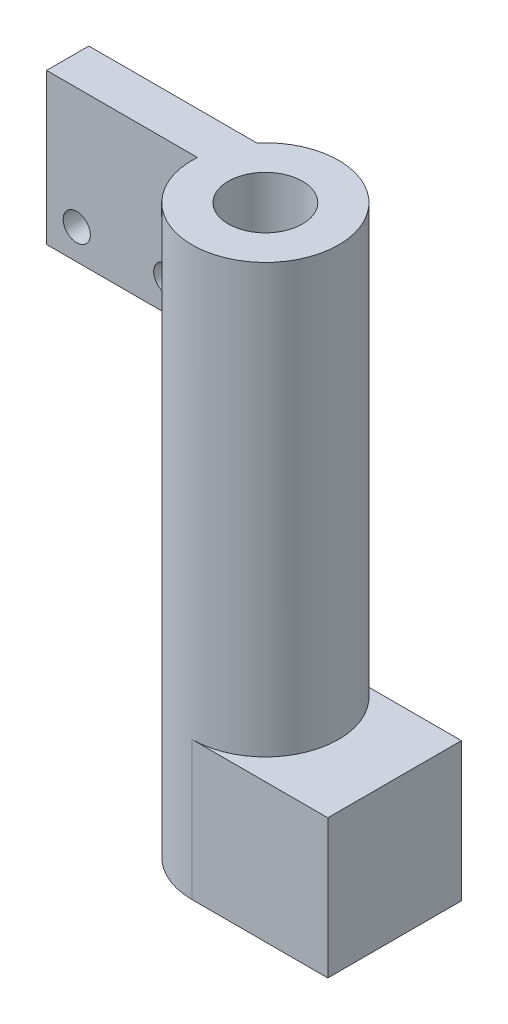
from build123d import *

# Parameters (mm, degrees)
SKETCH1_R                = 12.15
SKETCH1_R_2              = 6.15
EXTRUDE_THIN1_DEPTH      = 94
LIMIT_SWITCH_MOUNT_DEPTH = 25
SKETCH3_R                = 2.25
HEAT_SET_INSERTS_DEPTH   = 7
SKETCH4_W                = 22.5
SKETCH4_H                = 23
BOSS_EXTRUDE1_DEPTH      = 12.15
BOSS_EXTRUDE1_DEPTH_BACK = 10
SKETCH1_3_R              = 6.15
CUT_EXTRUDE1_DEPTH       = 94


with BuildPart() as part:
    # Sketch1 → Extrude-Thin1 (new body)
    with BuildSketch(Plane(origin=(0, 0, 0), x_dir=(1, 0, 0), z_dir=(0, 1, 0))):
        Circle(SKETCH1_R)
        Circle(SKETCH1_R_2, mode=Mode.SUBTRACT)
    extrude(amount=EXTRUDE_THIN1_DEPTH)

    # Sketch2 → limit switch mount (add)
    with BuildSketch(Plane(origin=(0, 94, 0), x_dir=(1, 0, 0), z_dir=(0, 1, 0))):
        with BuildLine():
            Line((-12.120231021, 0.85), (-37.120231021, 0.85))
            Line((-37.120231021, 0.85), (-37.120231021, 7.85))
            Line((-37.120231021, 7.85), (-9.273618495, 7.85))
            ThreePointArc((-9.273618495, 7.85), (-11.254963318, 4.576931365), (-12.120231021, 0.85))
        make_face()
    extrude(amount=-LIMIT_SWITCH_MOUNT_DEPTH)

    # Sketch3 → heat set inserts (cut)
    with BuildSketch(Plane.XY.offset(-0.85)):
        with Locations((-17.120231021, 74)):
            Circle(SKETCH3_R)
        with Locations((-32.120231021, 74)):
            Circle(SKETCH3_R)
    extrude(amount=-HEAT_SET_INSERTS_DEPTH, mode=Mode.SUBTRACT)

    # Sketch4 → Boss-Extrude1 (add, two sides)
    with BuildSketch(Plane.XY) as boss_extrude1_sk:
        with Locations((11.25, 11.5)):
            Rectangle(SKETCH4_W, SKETCH4_H)
    extrude(amount=BOSS_EXTRUDE1_DEPTH)
    extrude(boss_extrude1_sk.sketch, amount=-BOSS_EXTRUDE1_DEPTH_BACK)

    # Sketch1_3 → Cut-Extrude1 (cut)
    with BuildSketch(Plane(origin=(0, 0, 0), x_dir=(1, 0, 0), z_dir=(0, 1, 0))):
        Circle(SKETCH1_3_R)
    extrude(amount=CUT_EXTRUDE1_DEPTH, mode=Mode.SUBTRACT)


solid = part.part
